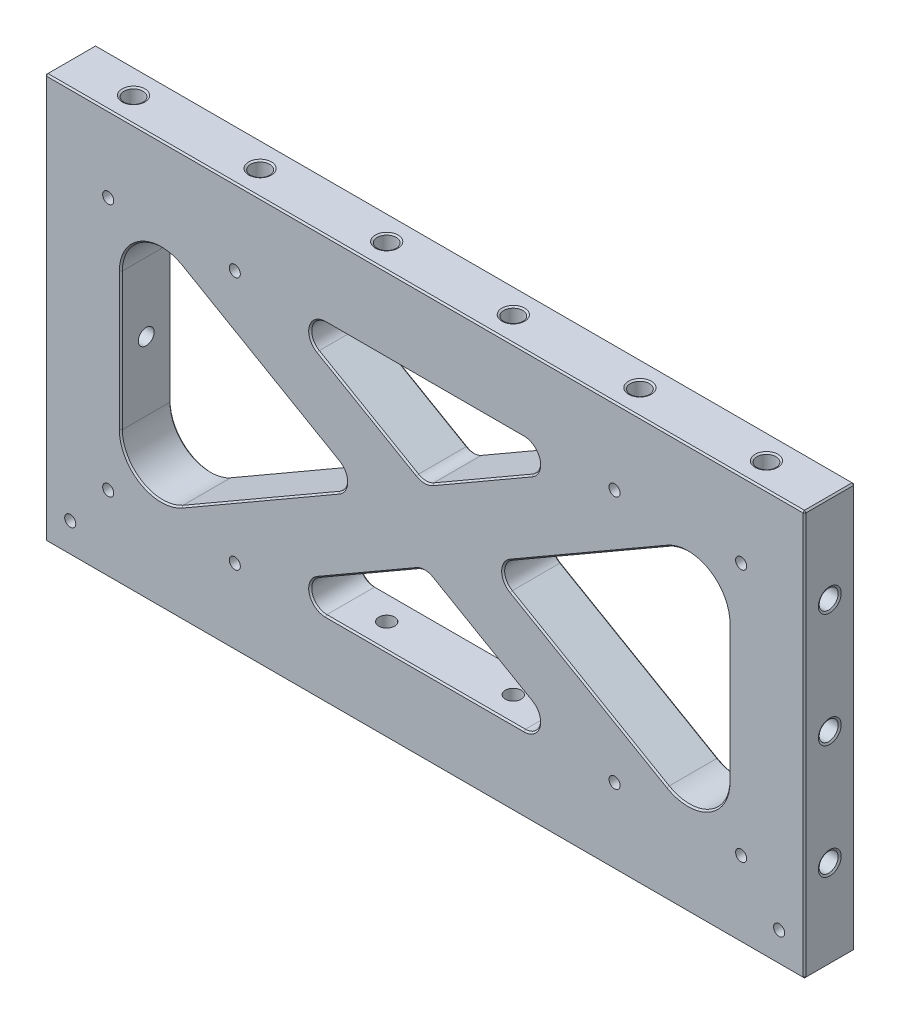
from build123d import *
from build123d.topology import SkipClean

# Parameters (mm, degrees)
SKETCH1_W                         = 381
SKETCH1_H                         = 203.2
EXTRUDE1_DEPTH                    = 12.7
SKETCH22_W                        = 304.8
SKETCH22_H                        = 127
EXTRUDE2_DEPTH                    = 26.4
EXTRUDE3_DEPTH                    = 25.4
EXTRUDE4_DEPTH                    = 25.4
FILLET2_R                         = 7.62
CHAMFER1_SIZE                     = 0.762
CHAMFER2_SIZE                     = 0.762
F_3_8_16_TAPPED_HOLE1_AT_2_COUNT  = 2
F_3_8_16_TAPPED_HOLE1_AT_2_PITCH  = 63.5
F_3_8_16_TAPPED_HOLE2_AT_2_COUNT  = 2
F_3_8_16_TAPPED_HOLE2_AT_2_PITCH  = 190.5
F_3_8_16_TAPPED_HOLE9_AT_2_COUNT  = 2
F_3_8_16_TAPPED_HOLE9_AT_2_PITCH  = 317.5
F_3_8_16_TAPPED_HOLE3_AT_2_COUNT  = 2
F_3_8_16_TAPPED_HOLE3_AT_2_PITCH  = 63.5
F_3_8_16_TAPPED_HOLE4_AT_2_COUNT  = 2
F_3_8_16_TAPPED_HOLE4_AT_2_PITCH  = 190.5
F_3_8_16_TAPPED_HOLE10_AT_2_COUNT = 2
F_3_8_16_TAPPED_HOLE10_AT_2_PITCH = 317.5
F_7_32_0_21875_VENT_HOLE1_D       = 5.55625
F_3_8_16_TAPPED_HOLE6_AT_2_COUNT  = 2
F_3_8_16_TAPPED_HOLE6_AT_2_PITCH  = 114.3
F_3_8_16_TAPPED_HOLE8_AT_2_COUNT  = 2
F_3_8_16_TAPPED_HOLE8_AT_2_PITCH  = 114.3
EXTRUDE20_DEPTH                   = 19.05
CHAMFER4_SIZE                     = 2.286
F_7_32_0_21875_DIAMETER_HOLE3_D   = 5.55625


with BuildPart() as part:
    # Sketch1 → Extrude1 (new body, symmetric)
    with BuildSketch(Plane.XY):
        with Locations((0, 101.6)):
            Rectangle(SKETCH1_W, SKETCH1_H)
    extrude(amount=EXTRUDE1_DEPTH, both=True)

    # Sketch22 → Extrude2 (cut, through all)
    with BuildSketch(Plane.XY.offset(12.7)):
        with Locations((0, 101.6)):
            Rectangle(SKETCH22_W, SKETCH22_H)
    extrude(amount=-EXTRUDE2_DEPTH, mode=Mode.SUBTRACT)

    # Sketch23 → Extrude3 (add)
    with BuildSketch(Plane.XY.offset(12.7)):
        Polygon((-141.735226281, 165.1), (78.235226281, 38.1), (141.735226281, 38.1), (-78.235226281, 165.1), align=None)
    extrude3 = extrude(amount=-EXTRUDE3_DEPTH)

    # Mirror2: Extrude3 across plane
    add(extrude3.mirror(Plane(origin=(0, 0, 0), x_dir=(0, 0, 1), z_dir=(1, 0, 0))))

    # Sketch25 → Extrude4 (add)
    with BuildSketch(Plane(origin=(0, 0, -12.7), x_dir=(-1, 0, 0), z_dir=(0, 0, -1))):
        with BuildLine():
            Line((-152.4, 136.062037568), (-152.4, 165.1))
            Line((-152.4, 165.1), (-141.735226281, 165.1))
            Line((-141.735226281, 165.1), (-121.92, 153.659673773))
            ThreePointArc((-121.92, 153.659673773), (-142.24, 153.659673773), (-152.4, 136.062037568))
        make_face()
        with BuildLine():
            Line((141.735226281, 165.1), (121.92, 153.659673773))
            ThreePointArc((121.92, 153.659673773), (142.24, 153.659673773), (152.4, 136.062037568))
            Line((152.4, 136.062037568), (152.4, 165.1))
            Line((152.4, 165.1), (141.735226281, 165.1))
        make_face()
        with BuildLine():
            Line((152.4, 67.137962432), (152.4, 38.1))
            Line((152.4, 38.1), (141.735226281, 38.1))
            Line((141.735226281, 38.1), (121.92, 49.540326227))
            ThreePointArc((121.92, 49.540326227), (142.24, 49.540326227), (152.4, 67.137962432))
        make_face()
        with BuildLine():
            Line((-141.735226281, 38.1), (-121.92, 49.540326227))
            ThreePointArc((-121.92, 49.540326227), (-142.24, 49.540326227), (-152.4, 67.137962432))
            Line((-152.4, 67.137962432), (-152.4, 38.1))
            Line((-152.4, 38.1), (-141.735226281, 38.1))
        make_face()
    extrude(amount=-EXTRUDE4_DEPTH)

    # Fillet2
    fillet2_edges = [part.edges().sort_by_distance(p)[0] for p in [
        (78.235226281, 38.1, 0),
        (-78.235226281, 165.1, 0),
        (0, 119.930871047, 0),
        (31.75, 101.6, 0),
        (0, 83.269128953, 0),
        (-31.75, 101.6, 0),
        (78.235226281, 165.1, 0),
        (-78.235226281, 38.1, 0),
    ]]
    fillet(fillet2_edges, radius=FILLET2_R)

    # Chamfer1
    chamfer1_edges = [part.edges().sort_by_distance(p)[0] for p in [
        (190.5, 101.6, 12.7),
        (0, 203.2, 12.7),
        (-190.5, 101.6, 12.7),
        (0, 203.2, -12.7),
        (190.5, 101.6, -12.7),
        (0, 0, -12.7),
        (-190.5, 101.6, -12.7),
        (0, 0, 12.7),
        (-190.5, 203.2, 0),
        (190.5, 203.2, 0),
        (190.5, 0, 0),
        (-190.5, 0, 0),
    ]]
    chamfer(chamfer1_edges, length=CHAMFER1_SIZE)

    # Chamfer2
    chamfer2_edges = [part.edges().sort_by_distance(p)[0] for p in [
        (-142.24, 49.540326227, -12.7),
        (-142.24, 49.540326227, 12.7),
        (152.4, 101.6, -12.7),
        (82.55, 72.270606325, -12.7),
        (82.55, 72.270606325, 12.7),
        (152.4, 101.6, 12.7),
        (142.24, 49.540326227, -12.7),
        (142.24, 49.540326227, 12.7),
        (-28.708499563, 136.505730998, 12.7),
        (-28.708499563, 136.505730998, -12.7),
        (0, 165.1, 12.7),
        (0, 165.1, -12.7),
        (28.708499563, 136.505730998, 12.7),
        (28.708499563, 136.505730998, -12.7),
        (28.708499563, 66.694269002, 12.7),
        (28.708499563, 66.694269002, -12.7),
        (-28.708499563, 66.694269002, 12.7),
        (-28.708499563, 66.694269002, -12.7),
        (0, 38.1, 12.7),
        (0, 38.1, -12.7),
        (-57.157353923, 159.452201124, 12.7),
        (-57.157353923, 159.452201124, -12.7),
        (57.157353923, 159.452201124, 12.7),
        (57.157353923, 159.452201124, -12.7),
        (0, 121.109689149, -12.7),
        (0, 121.109689149, 12.7),
        (0, 82.090310851, -12.7),
        (0, 82.090310851, 12.7),
        (57.157353923, 43.747798876, 12.7),
        (57.157353923, 43.747798876, -12.7),
        (-57.157353923, 43.747798876, 12.7),
        (-57.157353923, 43.747798876, -12.7),
        (-39.37, 101.6, 12.7),
        (-39.37, 101.6, -12.7),
        (39.37, 101.6, 12.7),
        (39.37, 101.6, -12.7),
        (82.55, 130.929393675, -12.7),
        (82.55, 130.929393675, 12.7),
        (142.24, 153.659673773, -12.7),
        (142.24, 153.659673773, 12.7),
        (-152.4, 101.6, 12.7),
        (-152.4, 101.6, -12.7),
        (-82.55, 130.929393675, -12.7),
        (-82.55, 130.929393675, 12.7),
        (-142.24, 153.659673773, -12.7),
        (-142.24, 153.659673773, 12.7),
        (-82.55, 72.270606325, -12.7),
        (-82.55, 72.270606325, 12.7),
    ]]
    chamfer(chamfer2_edges, length=CHAMFER2_SIZE)

    # Sketch6 → 3/8-16 Tapped Hole1 (revolve, cut)
    with BuildSketch(Plane(origin=(-31.75, 0, 0), x_dir=(0, 0, -1), z_dir=(1, 0, 0))):
        Polygon((0, 0), (0, 46.834665582), (3.96875, 44.45), (3.96875, 25.4), (4.7625, 25.4), (4.7625, 0.549926131), (5.715, 0), align=None)
    f_3_8_16_tapped_hole1 = revolve(axis=Axis((-31.75, -6.35, 0), (0, 1, 0)), mode=Mode.SUBTRACT)

    # 3/8-16 Tapped Hole1 at 2: 3/8-16 Tapped Hole1 ×2
    with Locations(*[(i * F_3_8_16_TAPPED_HOLE1_AT_2_PITCH, 0, 0) for i in range(1, F_3_8_16_TAPPED_HOLE1_AT_2_COUNT)]):
        add(f_3_8_16_tapped_hole1, mode=Mode.SUBTRACT)

    # Sketch48 → 3/8-16 Tapped Hole2 (revolve, cut)
    with BuildSketch(Plane(origin=(-95.25, 0, 0), x_dir=(0, 0, -1), z_dir=(1, 0, 0))):
        Polygon((0, 0), (0, 46.834665582), (3.96875, 44.45), (3.96875, 25.4), (4.7625, 25.4), (4.7625, 0.549926131), (5.715, 0), align=None)
    f_3_8_16_tapped_hole2 = revolve(axis=Axis((-95.25, -6.35, 0), (0, 1, 0)), mode=Mode.SUBTRACT)

    # 3/8-16 Tapped Hole2 at 2: 3/8-16 Tapped Hole2 ×2
    with Locations(*[(i * F_3_8_16_TAPPED_HOLE2_AT_2_PITCH, 0, 0) for i in range(1, F_3_8_16_TAPPED_HOLE2_AT_2_COUNT)]):
        add(f_3_8_16_tapped_hole2, mode=Mode.SUBTRACT)

    # Sketch57 → 3/8-16 Tapped Hole9 (revolve, cut)
    with BuildSketch(Plane(origin=(158.75, 0, 0), x_dir=(0, 0, -1), z_dir=(1, 0, 0))):
        Polygon((0, 0), (0, 46.834665582), (3.96875, 44.45), (3.96875, 25.4), (4.7625, 25.4), (4.7625, 0.549926131), (5.715, 0), align=None)
    f_3_8_16_tapped_hole9 = revolve(axis=Axis((158.75, -6.35, 0), (0, 1, 0)), mode=Mode.SUBTRACT)

    # 3/8-16 Tapped Hole9 at 2: 3/8-16 Tapped Hole9 ×2
    with Locations(*[(-i * F_3_8_16_TAPPED_HOLE9_AT_2_PITCH, 0, 0) for i in range(1, F_3_8_16_TAPPED_HOLE9_AT_2_COUNT)]):
        add(f_3_8_16_tapped_hole9, mode=Mode.SUBTRACT)

    # Sketch8 → 3/8-16 Tapped Hole3 (revolve, cut)
    with BuildSketch(Plane(origin=(-31.75, 203.2, 0), x_dir=(0, 0, 1), z_dir=(1, 0, 0))):
        Polygon((0, 0), (0, 46.834665582), (3.96875, 44.45), (3.96875, 25.4), (4.7625, 25.4), (4.7625, 0.549926131), (5.715, 0), align=None)
    f_3_8_16_tapped_hole3 = revolve(axis=Axis((-31.75, 209.55, 0), (0, -1, 0)), mode=Mode.SUBTRACT)

    # 3/8-16 Tapped Hole3 at 2: 3/8-16 Tapped Hole3 ×2
    with Locations(*[(i * F_3_8_16_TAPPED_HOLE3_AT_2_PITCH, 0, 0) for i in range(1, F_3_8_16_TAPPED_HOLE3_AT_2_COUNT)]):
        add(f_3_8_16_tapped_hole3, mode=Mode.SUBTRACT)

    # Sketch50 → 3/8-16 Tapped Hole4 (revolve, cut)
    with BuildSketch(Plane(origin=(95.25, 203.2, 0), x_dir=(0, 0, 1), z_dir=(1, 0, 0))):
        Polygon((0, 0), (0, 46.834665582), (3.96875, 44.45), (3.96875, 25.4), (4.7625, 25.4), (4.7625, 0.549926131), (5.715, 0), align=None)
    f_3_8_16_tapped_hole4 = revolve(axis=Axis((95.25, 209.55, 0), (0, -1, 0)), mode=Mode.SUBTRACT)

    # 3/8-16 Tapped Hole4 at 2: 3/8-16 Tapped Hole4 ×2
    with Locations(*[(-i * F_3_8_16_TAPPED_HOLE4_AT_2_PITCH, 0, 0) for i in range(1, F_3_8_16_TAPPED_HOLE4_AT_2_COUNT)]):
        add(f_3_8_16_tapped_hole4, mode=Mode.SUBTRACT)

    # Sketch59 → 3/8-16 Tapped Hole10 (revolve, cut)
    with BuildSketch(Plane(origin=(158.75, 203.2, 0), x_dir=(0, 0, 1), z_dir=(1, 0, 0))):
        Polygon((0, 0), (0, 46.834665582), (3.96875, 44.45), (3.96875, 25.4), (4.7625, 25.4), (4.7625, 0.549926131), (5.715, 0), align=None)
    f_3_8_16_tapped_hole10 = revolve(axis=Axis((158.75, 209.55, 0), (0, -1, 0)), mode=Mode.SUBTRACT)

    # 3/8-16 Tapped Hole10 at 2: 3/8-16 Tapped Hole10 ×2
    with Locations(*[(-i * F_3_8_16_TAPPED_HOLE10_AT_2_PITCH, 0, 0) for i in range(1, F_3_8_16_TAPPED_HOLE10_AT_2_COUNT)]):
        add(f_3_8_16_tapped_hole10, mode=Mode.SUBTRACT)

    # 7/32 (0.21875) Vent Hole1 (through all)
    with Locations(Plane(origin=(-328.933345796, 96.873522259, 12.7), x_dir=(-1, 0, 0), z_dir=(0, 0, 1))):
        with Locations((-487.683345796, 58.773522259), (-424.183345796, 58.773522259), (-233.683345796, 58.773522259), (-170.183345796, 58.773522259), (-487.683345796, -68.226477741), (-424.183345796, -68.226477741), (-233.683345796, -68.226477741), (-170.183345796, -68.226477741)):
            Hole(F_7_32_0_21875_VENT_HOLE1_D / 2)

    # Sketch18 → 3/8-16 Tapped Hole5 (revolve, cut)
    with BuildSketch(Plane(origin=(190.5, 101.6, 0), x_dir=(0, 0, -1), z_dir=(0, 1, 0))):
        Polygon((0, 0), (0, 40.484665582), (3.96875, 38.1), (3.96875, 25.4), (4.7625, 25.4), (4.7625, 0.549926131), (5.715, 0), align=None)
    revolve(axis=Axis((196.85, 101.6, 0), (-1, 0, 0)), mode=Mode.SUBTRACT)

    # Sketch52 → 3/8-16 Tapped Hole6 (revolve, cut)
    with SkipClean():  # keep this step's faces unmerged: merging them makes the solid invalid here
        with BuildSketch(Plane(origin=(190.5, 158.75, 0), x_dir=(0, 0, -1), z_dir=(0, 1, 0))):
            Polygon((0, 0), (0, 35.404665582), (3.96875, 33.02), (3.96875, 25.4), (4.7625, 25.4), (4.7625, 0.549926131), (5.715, 0), align=None)
        f_3_8_16_tapped_hole6 = revolve(axis=Axis((196.85, 158.75, 0), (-1, 0, 0)), mode=Mode.SUBTRACT)

    # 3/8-16 Tapped Hole6 at 2: 3/8-16 Tapped Hole6 ×2
    with Locations(*[(0, -i * F_3_8_16_TAPPED_HOLE6_AT_2_PITCH, 0) for i in range(1, F_3_8_16_TAPPED_HOLE6_AT_2_COUNT)]):
        add(f_3_8_16_tapped_hole6, mode=Mode.SUBTRACT)

    # Sketch20 → 3/8-16 Tapped Hole7 (revolve, cut)
    with BuildSketch(Plane(origin=(-190.5, 101.6, 0), x_dir=(0, 0, 1), z_dir=(0, 1, 0))):
        Polygon((0, 0), (0, 40.484665582), (3.96875, 38.1), (3.96875, 25.4), (4.7625, 25.4), (4.7625, 0.549926131), (5.715, 0), align=None)
    revolve(axis=Axis((-196.85, 101.6, 0), (1, 0, 0)), mode=Mode.SUBTRACT)

    # Sketch55 → 3/8-16 Tapped Hole8 (revolve, cut)
    with BuildSketch(Plane(origin=(-190.5, 158.75, 0), x_dir=(0, 0, 1), z_dir=(0, 1, 0))):
        Polygon((0, 0), (0, 35.404665582), (3.96875, 33.02), (3.96875, 25.4), (4.7625, 25.4), (4.7625, 0.549926131), (5.715, 0), align=None)
    f_3_8_16_tapped_hole8 = revolve(axis=Axis((-196.85, 158.75, 0), (1, 0, 0)), mode=Mode.SUBTRACT)

    # 3/8-16 Tapped Hole8 at 2: 3/8-16 Tapped Hole8 ×2
    with Locations(*[(0, -i * F_3_8_16_TAPPED_HOLE8_AT_2_PITCH, 0) for i in range(1, F_3_8_16_TAPPED_HOLE8_AT_2_COUNT)]):
        add(f_3_8_16_tapped_hole8, mode=Mode.SUBTRACT)

    # Sketch45 → Extrude20 (cut)
    with BuildSketch(Plane.XZ):
        with BuildLine():
            Line((-179.3875, 4.77139), (-176.2125, 4.77139))
            ThreePointArc((-176.2125, 4.77139), (-171.44111, 0), (-176.2125, -4.77139))
            Line((-176.2125, -4.77139), (-179.3875, -4.77139))
            ThreePointArc((-179.3875, -4.77139), (-184.15889, 0), (-179.3875, 4.77139))
        make_face()
        with BuildLine():
            Line((179.3875, 4.77139), (176.2125, 4.77139))
            ThreePointArc((176.2125, 4.77139), (171.44111, 0), (176.2125, -4.77139))
            Line((176.2125, -4.77139), (179.3875, -4.77139))
            ThreePointArc((179.3875, -4.77139), (184.15889, 0), (179.3875, 4.77139))
        make_face()
    extrude(amount=-EXTRUDE20_DEPTH, mode=Mode.SUBTRACT)

    # Chamfer4
    chamfer4_edges = [part.edges().sort_by_distance(p)[0] for p in [
        (-184.15889, 0, 0),
        (-177.8, 0, -4.77139),
        (-171.44111, 0, 0),
        (-177.8, 0, 4.77139),
        (184.15889, 0, 0),
        (177.8, 0, 4.77139),
        (171.44111, 0, 0),
        (177.8, 0, -4.77139),
    ]]
    chamfer(chamfer4_edges, length=CHAMFER4_SIZE)

    # 7/32 (0.21875) Diameter Hole3 (through all)
    with Locations(Plane.XY.offset(12.7)):
        with Locations((177.8, 15.24), (-177.8, 15.24)):
            Hole(F_7_32_0_21875_DIAMETER_HOLE3_D / 2)


solid = part.part
